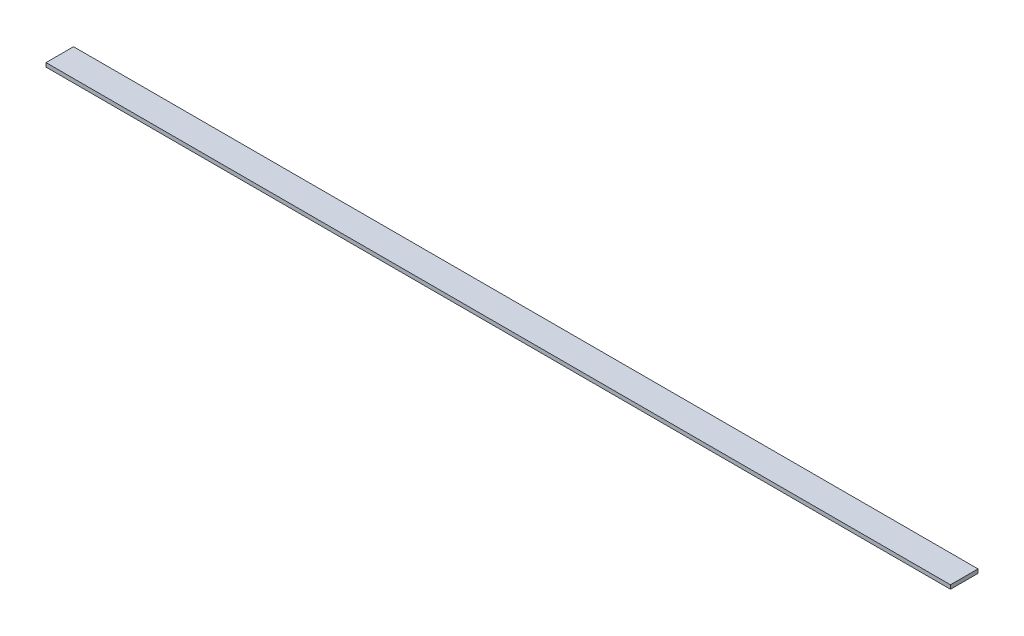
from build123d import *

# Parameters (mm, degrees)
SKETCH1_W           = 2921
SKETCH1_H           = 88.9
BOSS_EXTRUDE1_DEPTH = 12.7


with BuildPart() as part:
    # Sketch1 → Boss-Extrude1 (new body)
    with BuildSketch(Plane(origin=(0, 0, 0), x_dir=(1, 0, 0), z_dir=(0, 1, 0))):
        with Locations((1351.077744586, -14.807568904)):
            Rectangle(SKETCH1_W, SKETCH1_H)
    extrude(amount=BOSS_EXTRUDE1_DEPTH)


solid = part.part
